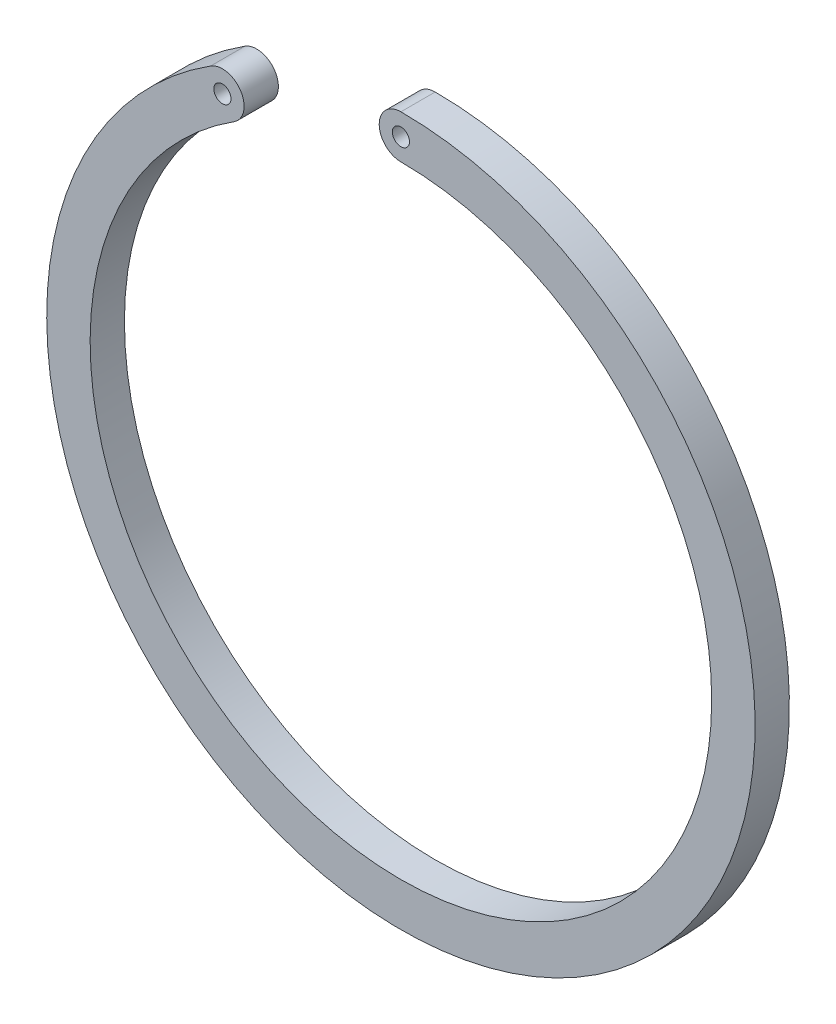
from build123d import *

# Parameters (mm, degrees)
SKETCH1_R           = 0.75
BOSS_EXTRUDE1_DEPTH = 3


with BuildPart() as part:
    # Sketch1 → Boss-Extrude1 (new body)
    with BuildSketch(Plane.XY):
        with BuildLine():
            ThreePointArc((0, 27.2), (19.233304448, 19.233304448), (27.2, 0))
            ThreePointArc((27.2, 0), (-13.088306987, -23.843997572), (-14.60413384, 22.946879413))
            ThreePointArc((-14.60413384, 22.946879413), (-14.021368524, 25.569928133), (-16.644417244, 26.152693449))
            ThreePointArc((-16.644417244, 26.152693449), (8.667943905, -29.763513711), (0, 31))
            ThreePointArc((0, 31), (-1.9, 29.1), (0, 27.2))
        make_face()
        with Locations((-15.624275542, 24.549786431)):
            Circle(SKETCH1_R, mode=Mode.SUBTRACT)
        with Locations((0, 29.1)):
            Circle(SKETCH1_R, mode=Mode.SUBTRACT)
    extrude(amount=BOSS_EXTRUDE1_DEPTH)


solid = part.part
